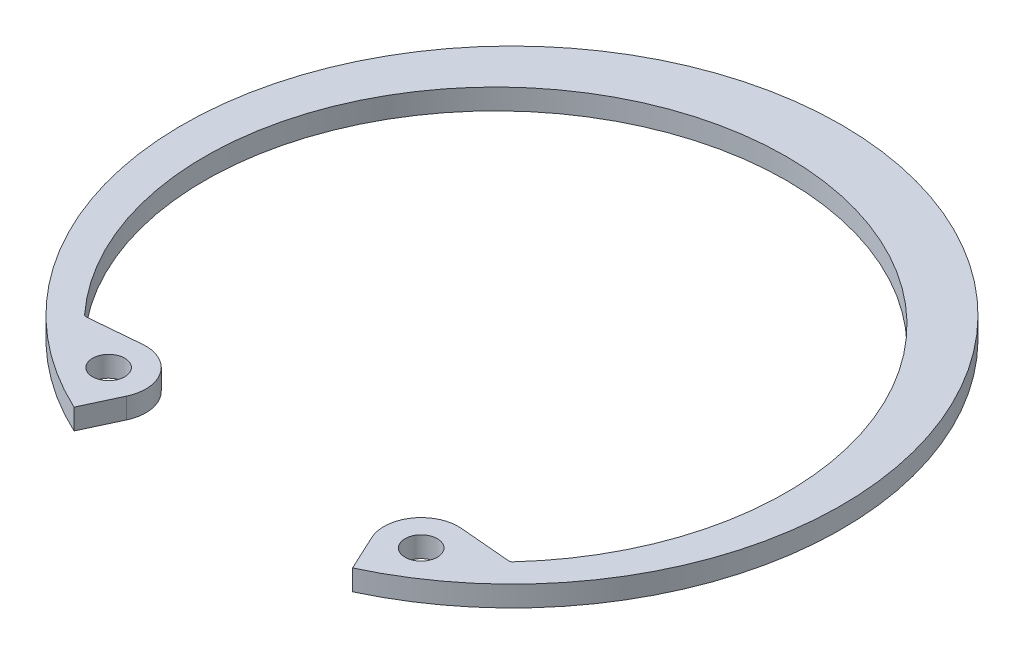
from build123d import *

# Parameters (mm, degrees)
SKETCH2_R      = 0.9906
EXTRUDE1_DEPTH = 1.27
FILLET1_R      = 0.254


with BuildPart() as part:
    # Sketch2 → Extrude1 (new body)
    with BuildSketch(Plane(origin=(0, 0, 0), x_dir=(1, 0, 0), z_dir=(0, 1, 0))):
        with BuildLine():
            Line((8.555399567, -18.347113579), (7.527551211, -16.142885666))
            ThreePointArc((7.527551211, -16.142885666), (7.726789239, -13.865584586), (9.79860884, -12.899479239))
            Line((9.79860884, -12.899479239), (13.072145972, -13.185876628))
            ThreePointArc((13.072145972, -13.185876628), (0, 16.8656), (-13.072145972, -13.185876628))
            Line((-13.072145972, -13.185876628), (-9.79860884, -12.899479239))
            ThreePointArc((-9.79860884, -12.899479239), (-7.726789239, -13.865584586), (-7.527551211, -16.142885666))
            Line((-7.527551211, -16.142885666), (-8.555399567, -18.347113579))
            ThreePointArc((-8.555399567, -18.347113579), (0, 20.2438), (8.555399567, -18.347113579))
        make_face()
        with Locations((9.599370812, -15.176780319)):
            Circle(SKETCH2_R, mode=Mode.SUBTRACT)
        with Locations((-9.599370812, -15.176780319)):
            Circle(SKETCH2_R, mode=Mode.SUBTRACT)
    extrude(amount=-EXTRUDE1_DEPTH)

    # Fillet1
    fillet1_edges = [part.edges().sort_by_distance(p)[0] for p in [
        (13.072145972, -0.635, 13.185876628),
        (-13.072145972, -0.635, 13.185876628),
    ]]
    fillet(fillet1_edges, radius=FILLET1_R)


solid = part.part
